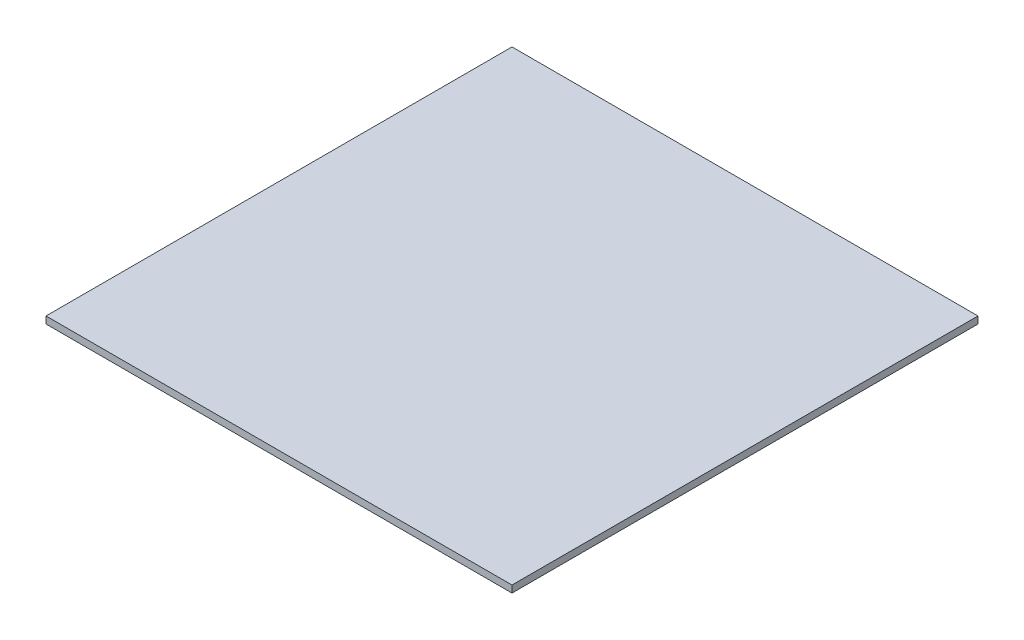
from build123d import *

# Parameters (mm, degrees)
SKETCH_1_W      = 200
SKETCH_1_H      = 200
EXTRUDE_1_DEPTH = 3


with BuildPart() as part:
    # 스케치1 → 보스-돌출1 (new body)
    with BuildSketch(Plane(origin=(0, 0, 0), x_dir=(1, 0, 0), z_dir=(0, 1, 0))):
        Rectangle(SKETCH_1_W, SKETCH_1_H)
    extrude(amount=EXTRUDE_1_DEPTH)


solid = part.part
